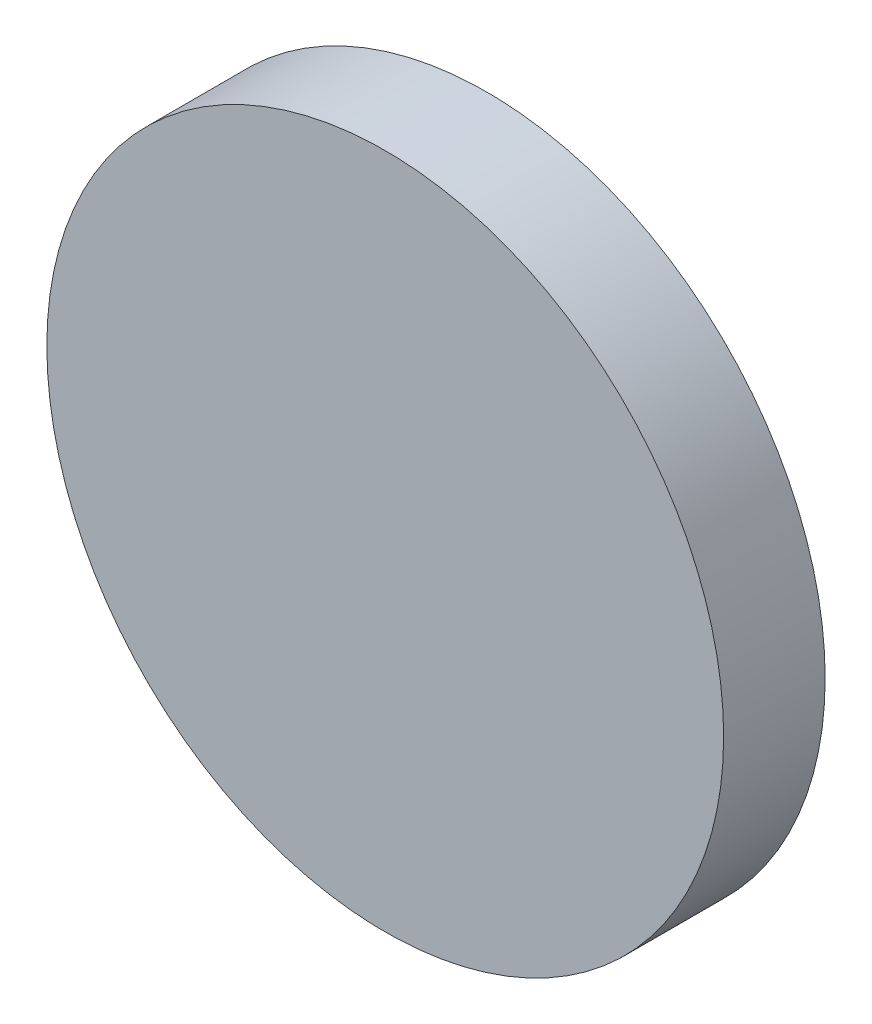
from build123d import *

# Parameters (mm, degrees)
SKETCH_1_R      = 10
EXTRUDE_1_DEPTH = 3


with BuildPart() as part:
    # 草图1 → 凸台-拉伸1 (new body)
    with BuildSketch(Plane.XY):
        Circle(SKETCH_1_R)
    extrude(amount=EXTRUDE_1_DEPTH)


solid = part.part
